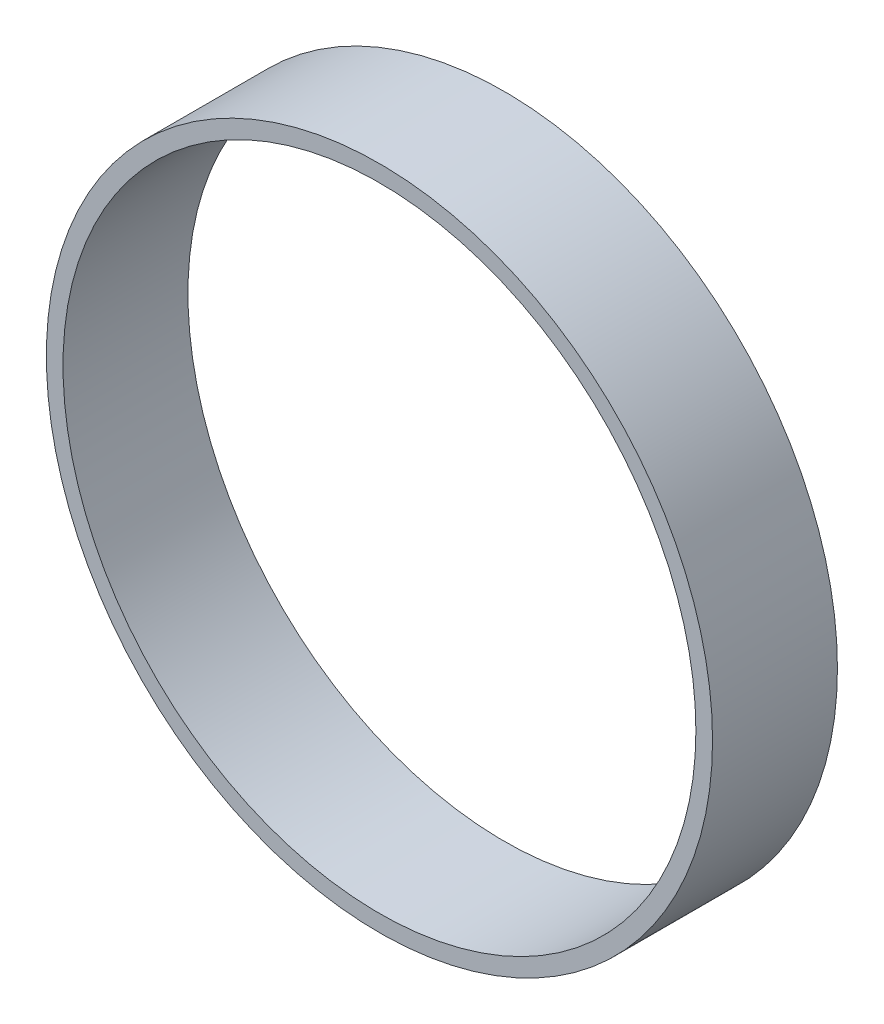
from build123d import *

# Parameters (mm, degrees)
SKETCH2_R           = 40000
SKETCH2_R_2         = 38000
BOSS_EXTRUDE2_DEPTH = 15000


with BuildPart() as part:
    # Sketch2 → Boss-Extrude2 (new body)
    with BuildSketch(Plane.XY):
        Circle(SKETCH2_R)
        Circle(SKETCH2_R_2, mode=Mode.SUBTRACT)
    extrude(amount=BOSS_EXTRUDE2_DEPTH)


solid = part.part
